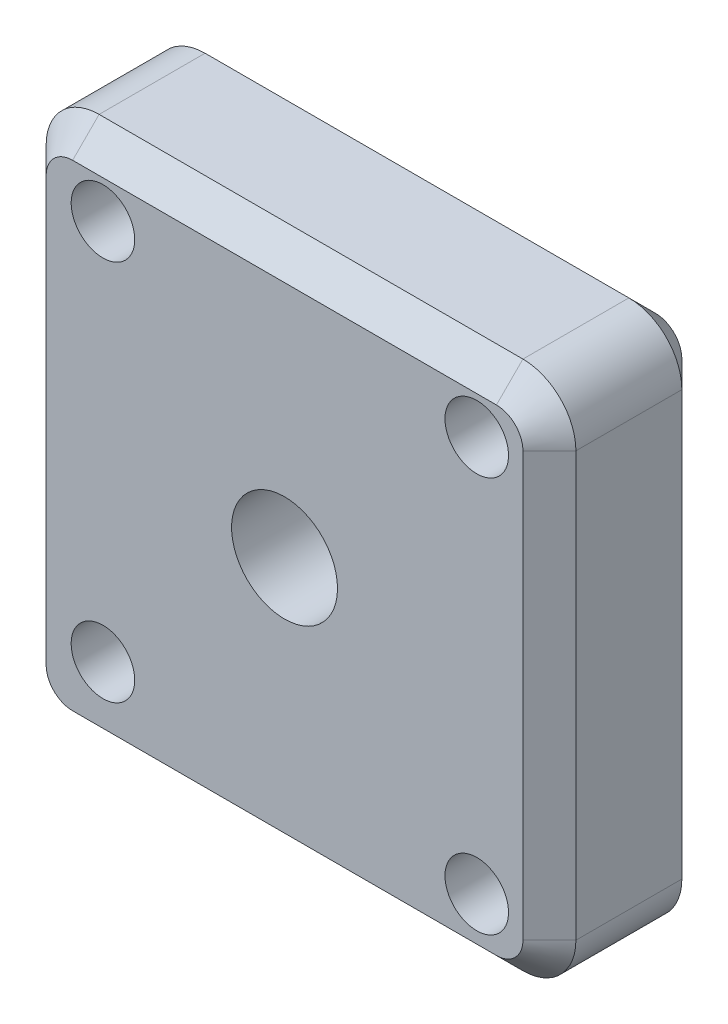
from build123d import *

# Parameters (mm, degrees)
SKETCH1_W                        = 100
SKETCH1_H                        = 100
BOSS_EXTRUDE1_DEPTH              = 30
CUT_EXTRUDE1_DEPTH               = 19
CUT_EXTRUDE1_DEPTH_BACK          = 77.811457479
SKETCH3_R                        = 10
FILLET1_R                        = 10
CHAMFER1_SIZE                    = 5
F_12_0MM_DOWEL_HOLE1_D           = 12
F_12_0MM_DOWEL_HOLE1_CSINK_D     = 12.05
F_12_0MM_DOWEL_HOLE1_CSINK_ANGLE = 90


with BuildPart() as part:
    # Sketch1 → Boss-Extrude1 (new body)
    with BuildSketch(Plane.XY):
        Rectangle(SKETCH1_W, SKETCH1_H)
    extrude(amount=BOSS_EXTRUDE1_DEPTH)

    # Sketch3 → Cut-Extrude1 (cut, two sides: drawn at the far end of the back side and taken through both)
    with BuildSketch(Plane.XY.offset(30).offset(-CUT_EXTRUDE1_DEPTH_BACK)):
        Circle(SKETCH3_R)
    extrude(amount=CUT_EXTRUDE1_DEPTH + CUT_EXTRUDE1_DEPTH_BACK, mode=Mode.SUBTRACT)

    # Fillet1
    fillet1_edges = [part.edges().sort_by_distance(p)[0] for p in [
        (-50, -50, 15),
        (-50, 50, 15),
        (50, 50, 15),
        (50, -50, 15),
    ]]
    fillet(fillet1_edges, radius=FILLET1_R)

    # Chamfer1
    chamfer1_edges = [part.edges().sort_by_distance(p)[0] for p in [
        (0, 50, 0),
        (-47.071067812, 47.071067812, 0),
        (47.071067812, 47.071067812, 0),
        (-50, 0, 0),
        (50, 0, 0),
        (-47.071067812, -47.071067812, 0),
        (47.071067812, -47.071067812, 0),
        (0, -50, 0),
        (50, 0, 30),
        (47.071067812, 47.071067812, 30),
        (47.071067812, -47.071067812, 30),
        (0, 50, 30),
        (0, -50, 30),
        (-47.071067812, 47.071067812, 30),
        (-47.071067812, -47.071067812, 30),
        (-50, 0, 30),
    ]]
    chamfer(chamfer1_edges, length=CHAMFER1_SIZE)

    # Ø12.0mm Dowel Hole1 (through all)
    with Locations(Plane(origin=(0, 0, 0), x_dir=(-1, 0, 0), z_dir=(0, 0, -1))):
        with Locations((-36.283625915, 37.887322089), (34.279005699, 37.887322089), (34.279005699, -34.145364351), (-36.283625915, -36.818191306)):
            CounterSinkHole(F_12_0MM_DOWEL_HOLE1_D / 2, F_12_0MM_DOWEL_HOLE1_CSINK_D / 2, counter_sink_angle=F_12_0MM_DOWEL_HOLE1_CSINK_ANGLE)


solid = part.part
